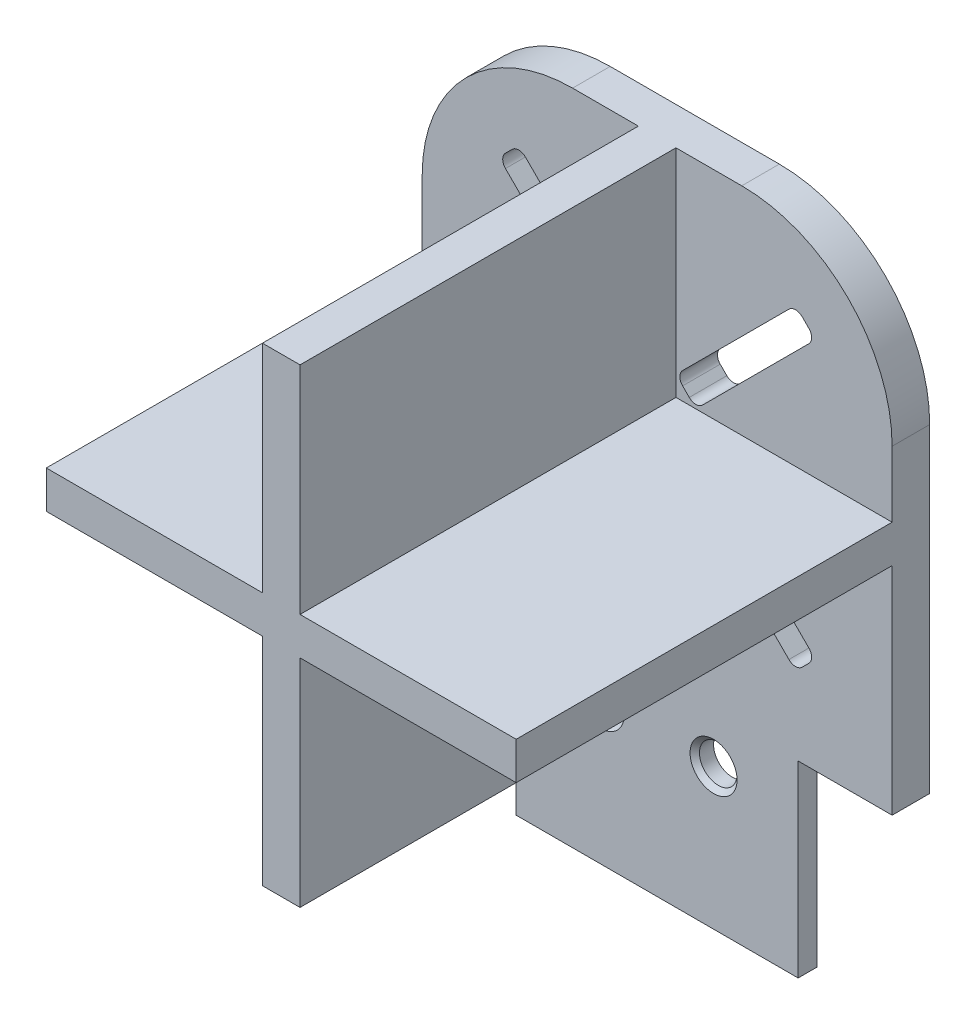
from build123d import *

# Parameters (mm, degrees)
SZKIC2_W                    = 25
SZKIC2_H                    = 25
DODANIE_WYCI_GNI_CIE1_DEPTH = 2
DODANIE_WYCI_GNI_CIE2_DEPTH = 20
ZAOKR_GLENIE1_R             = 8
WYTNIJ_WYCI_GNI_CIE1_DEPTH  = 20
ZAOKR_GLENIE2_R             = 0.5
WYTNIJ_WYCI_GNI_CIE2_DEPTH  = 20
WYTNIJ_WYCI_GNI_CIE3_DEPTH  = 20
WYTNIJ_WYCI_GNI_CIE4_DEPTH  = 20
ZAOKR_GLENIE3_R             = 0.5
SZKIC14_W                   = 15
SZKIC14_H                   = 10
DODANIE_WYCI_GNI_CIE3_DEPTH = 1
SZKIC13_R                   = 1
WYTNIJ_WYCI_GNI_CIE5_DEPTH  = 1
SFAZOWANIE1_SIZE            = 0.25


with BuildPart() as part:
    # Szkic2 → Dodanie-wyciągnięcie1 (new body)
    with BuildSketch(Plane.XY):
        with Locations((12.5, -12.5)):
            Rectangle(SZKIC2_W, SZKIC2_H)
    extrude(amount=DODANIE_WYCI_GNI_CIE1_DEPTH)

    # Szkic3 → Dodanie-wyciągnięcie2 (add)
    with BuildSketch(Plane.XY.offset(2)):
        Polygon((11.5, 0), (13.5, 0), (13.5, -11.5), (25, -11.5), (25, -13.5), (13.5, -13.5), (13.5, -25), (11.5, -25), (11.5, -13.5), (0, -13.5), (0, -11.5), (11.5, -11.5), align=None)
    extrude(amount=DODANIE_WYCI_GNI_CIE2_DEPTH)

    # Zaokrąglenie1
    zaokr_glenie1_edges = [part.edges().sort_by_distance(p)[0] for p in [
        (0, 0, 1),
        (25, 0, 1),
    ]]
    fillet(zaokr_glenie1_edges, radius=ZAOKR_GLENIE1_R)

    # Szkic7 → Wytnij-wyciągnięcie1 (cut)
    with BuildSketch(Plane.XY.offset(2)):
        Polygon((10.439339828, -13.5), (11.5, -14.560660172), (5.136038969, -20.924621202), (4.075378798, -19.863961031), align=None)
    extrude(amount=-WYTNIJ_WYCI_GNI_CIE1_DEPTH, mode=Mode.SUBTRACT)

    # Zaokrąglenie2
    zaokr_glenie2_edges = [part.edges().sort_by_distance(p)[0] for p in [
        (4.075378798, -19.863961031, 1),
        (10.439339828, -13.5, 1),
        (11.5, -14.560660172, 1),
        (5.136038969, -20.924621202, 1),
    ]]
    fillet(zaokr_glenie2_edges, radius=ZAOKR_GLENIE2_R)

    # Szkic9 → Wytnij-wyciągnięcie2 (cut)
    with BuildSketch(Plane.XY.offset(2)):
        Polygon((11.5, -10.439339828), (10.439339828, -11.5), (4.075378798, -5.136038969), (5.136038969, -4.075378798), align=None)
    extrude(amount=-WYTNIJ_WYCI_GNI_CIE2_DEPTH, mode=Mode.SUBTRACT)

    # Szkic11 → Wytnij-wyciągnięcie3 (cut)
    with BuildSketch(Plane.XY.offset(2)):
        Polygon((13.5, -10.439339828), (14.560660172, -11.5), (20.924621202, -5.136038969), (19.863961031, -4.075378798), align=None)
    extrude(amount=-WYTNIJ_WYCI_GNI_CIE3_DEPTH, mode=Mode.SUBTRACT)

    # Szkic12 → Wytnij-wyciągnięcie4 (cut)
    with BuildSketch(Plane.XY.offset(2)):
        Polygon((14.560660172, -13.5), (13.5, -14.560660172), (19.863961031, -20.924621202), (20.924621202, -19.863961031), align=None)
    extrude(amount=-WYTNIJ_WYCI_GNI_CIE4_DEPTH, mode=Mode.SUBTRACT)

    # Zaokrąglenie3
    zaokr_glenie3_edges = [part.edges().sort_by_distance(p)[0] for p in [
        (5.136038969, -4.075378798, 1),
        (11.5, -10.439339828, 1),
        (10.439339828, -11.5, 1),
        (4.075378798, -5.136038969, 1),
        (13.5, -10.439339828, 1),
        (19.863961031, -4.075378798, 1),
        (20.924621202, -5.136038969, 1),
        (14.560660172, -11.5, 1),
        (14.560660172, -13.5, 1),
        (20.924621202, -19.863961031, 1),
        (19.863961031, -20.924621202, 1),
        (13.5, -14.560660172, 1),
    ]]
    fillet(zaokr_glenie3_edges, radius=ZAOKR_GLENIE3_R)

    # Szkic14 → Dodanie-wyciągnięcie3 (add)
    with BuildSketch(Plane.XY.offset(2)):
        with Locations((12.5, -30)):
            Rectangle(SZKIC14_W, SZKIC14_H)
    extrude(amount=-DODANIE_WYCI_GNI_CIE3_DEPTH)

    # Szkic13 → Wytnij-wyciągnięcie5 (cut)
    with BuildSketch(Plane.XY.offset(2)):
        with Locations((9.5, -27.5)):
            Circle(SZKIC13_R)
        with Locations((15.5, -27.5)):
            Circle(SZKIC13_R)
    extrude(amount=-WYTNIJ_WYCI_GNI_CIE5_DEPTH, mode=Mode.SUBTRACT)

    # Sfazowanie1
    sfazowanie1_edges = [part.edges().sort_by_distance(p)[0] for p in [
        (8.5, -27.5, 2),
        (14.5, -27.5, 2),
    ]]
    chamfer(sfazowanie1_edges, length=SFAZOWANIE1_SIZE)


solid = part.part
